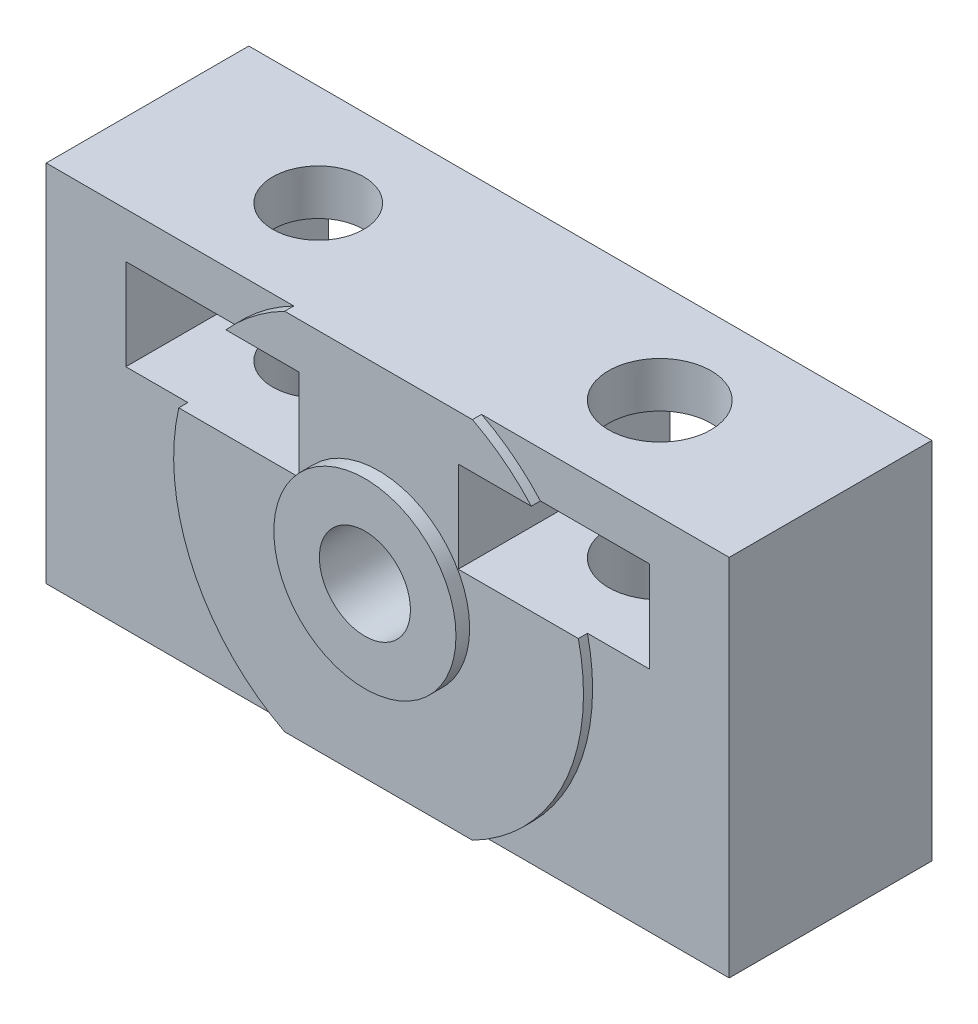
from build123d import *

# Parameters (mm, degrees)
SKETCH_1_W               = 30
SKETCH_1_H               = 16
SKETCH_1_R               = 2
EXTRUDE_1_DEPTH          = 8.9
SKETCH_2_R               = 2
SKETCH_2_R_2             = 2.25
CUT_EXTRUDE_1_DEPTH      = 18
SKETCH_3_W               = 8
SKETCH_3_H               = 4
CUT_EXTRUDE_2_DEPTH      = 2
CUT_EXTRUDE_2_DEPTH_BACK = 9.9
CUT_EXTRUDE_4_DEPTH      = 10.9


with BuildPart() as part:
    # Эскиз1 → Бобышка-Вытянуть1 (new body)
    with BuildSketch(Plane.XY):
        Rectangle(SKETCH_1_W, SKETCH_1_H)
        Circle(SKETCH_1_R, mode=Mode.SUBTRACT)
    extrude(amount=EXTRUDE_1_DEPTH)

    # Эскиз5 → Повернуть1 (revolve)
    with BuildSketch(Plane(origin=(0, 0, 0), x_dir=(-1, 0, 0), z_dir=(0, 1, 0))):
        Polygon((2, 8.9), (2, 9.9), (4, 9.9), (4, 9.3), (9, 9.3), (9, 8.9), align=None)
    revolve(axis=Axis((0, 0, 8.9), (0, 0, -1)))

    # Эскиз2 → Вырез-Вытянуть1 (cut, through all)
    with BuildSketch(Plane.XZ.offset(8)):
        with Locations((-7.5, 4.45)):
            Circle(SKETCH_2_R)
        with Locations((7.5, 4.45)):
            Circle(SKETCH_2_R_2)
    extrude(amount=-CUT_EXTRUDE_1_DEPTH, mode=Mode.SUBTRACT)

    # Эскиз3 → Вырез-Вытянуть2 (cut, two sides)
    with BuildSketch(Plane.XY.offset(8.9)) as cut_extrude_2_sk:
        with Locations((-7.5, 4)):
            Rectangle(SKETCH_3_W, SKETCH_3_H)
        with Locations((7.5, 4)):
            Rectangle(SKETCH_3_W, SKETCH_3_H)
    extrude(amount=CUT_EXTRUDE_2_DEPTH, mode=Mode.SUBTRACT)
    extrude(cut_extrude_2_sk.sketch, amount=-CUT_EXTRUDE_2_DEPTH_BACK, mode=Mode.SUBTRACT)

    # Эскиз7 → Вырез-Вытянуть4 (cut, through all)
    with BuildSketch(Plane(origin=(0, 0, 0), x_dir=(-1, 0, 0), z_dir=(0, 0, -1))):
        with BuildLine():
            Line((-4.123105626, 8), (4.123105626, 8))
            ThreePointArc((4.123105626, 8), (0, 9), (-4.123105626, 8))
        make_face()
        with BuildLine():
            ThreePointArc((-4.123105626, -8), (0, -9), (4.123105626, -8))
            Line((4.123105626, -8), (-4.123105626, -8))
        make_face()
    extrude(amount=-CUT_EXTRUDE_4_DEPTH, mode=Mode.SUBTRACT)


solid = part.part
